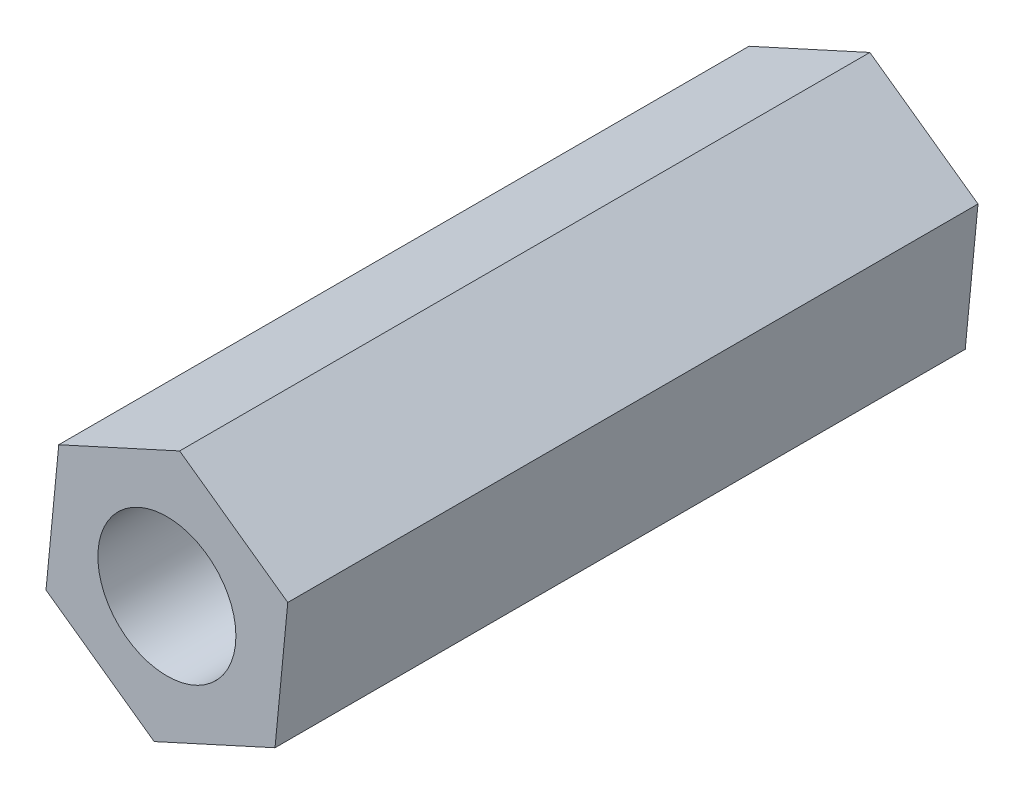
from build123d import *

# Parameters (mm, degrees)
SZKIC1_R                    = 1.5
DODANIE_WYCI_GNI_CIE1_DEPTH = 15


with BuildPart() as part:
    # Szkic1 → Dodanie-wyciągnięcie1 (new body)
    with BuildSketch(Plane.XY):
        Polygon((2.627001114, 1.196744952), (0.277089027, 2.873422177), (-2.349912087, 1.676677225), (-2.627001114, -1.196744952), (-0.277089027, -2.873422177), (2.349912087, -1.676677225), align=None)
        Circle(SZKIC1_R, mode=Mode.SUBTRACT)
    extrude(amount=DODANIE_WYCI_GNI_CIE1_DEPTH)


solid = part.part
